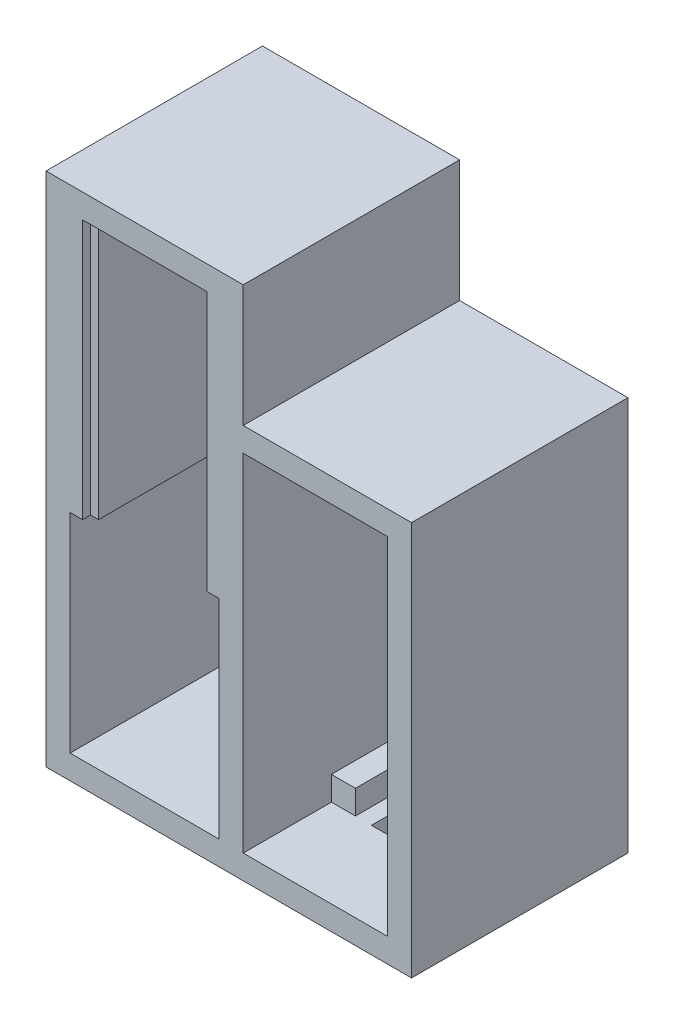
from build123d import *

# Parameters (mm, degrees)
SKETCH1_W            = 24.6
SKETCH1_H            = 64.4
BOSS_EXTRUDE1_DEPTH  = 3
SKETCH1_5_W          = 24.6
SKETCH1_5_H          = 64.4
BOSS_EXTRUDE2_DEPTH  = 26
BOSS_EXTRUDE4_DEPTH  = 35
SKETCH1_8_W          = 24.6
SKETCH1_8_H          = 64.4
BOSS_EXTRUDE5_DEPTH  = 27
BOSS_EXTRUDE6_DEPTH  = 3
BOSS_EXTRUDE7_DEPTH  = 2
SKETCH2_4_W          = 8
SKETCH2_4_H          = 3
BOSS_EXTRUDE8_DEPTH  = 11
SKETCH2_5_W          = 5
SKETCH2_5_H          = 3
BOSS_EXTRUDE9_DEPTH  = 27
SKETCH5_W            = 33.6
SKETCH5_H            = 60.4
BOSS_EXTRUDE11_DEPTH = 3
SKETCH5_5_W          = 30.618778274
SKETCH5_5_H          = 54.4
CUT_EXTRUDE3_DEPTH   = 3
BOSS_EXTRUDE12_DEPTH = 27
SKETCH6_W            = 30.618778274
SKETCH6_H            = 47.4
BOSS_EXTRUDE13_DEPTH = 3
SKETCH7_W            = 24.6
SKETCH7_H            = 8
CUT_EXTRUDE4_DEPTH   = 3
SKETCH8_W            = 11
SKETCH8_H            = 3
BOSS_EXTRUDE14_DEPTH = 8
SKETCH2_6_W          = 3
SKETCH2_6_H          = 3
SKETCH2_6_W_2        = 5
BOSS_EXTRUDE15_DEPTH = 16
SKETCH9_W            = 36.6
SKETCH9_H            = 3
BOSS_EXTRUDE16_DEPTH = 15
SKETCH10_W           = 18.8
SKETCH10_H           = 11.60179211
CUT_EXTRUDE5_DEPTH   = 15
BOSS_EXTRUDE17_DEPTH = 3
BOSS_EXTRUDE18_DEPTH = 3
SKETCH13_W           = 33.6
SKETCH13_H           = 60.4
CUT_EXTRUDE6_DEPTH   = 70
CUT_EXTRUDE7_DEPTH   = 70


with BuildPart() as part:
    # Sketch1 → Boss-Extrude1 (new body)
    with BuildSketch(Plane.XY):
        with Locations((-9.3, 29.2)):
            Rectangle(SKETCH1_W, SKETCH1_H)
    extrude(amount=BOSS_EXTRUDE1_DEPTH)

    # Sketch1_5 → Boss-Extrude2 (add)
    with BuildSketch(Plane.XY):
        with Locations((-9.3, 29.2)):
            Rectangle(SKETCH1_5_W, SKETCH1_5_H)
        Polygon((0, 0), (-18.6, 0), (-18.6, 26), (-16.05, 26), (-16.05, 58.4), (-2.55, 58.4), (-2.55, 26), (0, 26), align=None, mode=Mode.SUBTRACT)
    extrude(amount=BOSS_EXTRUDE2_DEPTH)

    # Sketch1_7 → Boss-Extrude4 (add)
    with BuildSketch(Plane.XY):
        Polygon((3, 0), (0, 0), (-18.6, 0), (-21.6, 0), (-21.6, -3), (3, -3), align=None)
    extrude(amount=BOSS_EXTRUDE4_DEPTH)

    # Sketch1_8 → Boss-Extrude5 (add)
    with BuildSketch(Plane.XY):
        with Locations((-9.3, 29.2)):
            Rectangle(SKETCH1_8_W, SKETCH1_8_H)
        Polygon((0, 0), (-18.6, 0), (-18.6, 26), (-17.05, 26), (-17.05, 58.4), (-1.55, 58.4), (-1.55, 26), (0, 26), align=None, mode=Mode.SUBTRACT)
    extrude(amount=BOSS_EXTRUDE5_DEPTH)

    # Sketch2 → Boss-Extrude6 (add)
    with BuildSketch(Plane(origin=(0, 0, 0), x_dir=(-1, 0, 0), z_dir=(0, 0, -1))):
        Polygon((-8, 0), (-6, 0), (-6, 3), (-3, 3), (-3, 40.2), (-8, 40.2), (-8, 43.2), (-16, 43.2), (-16, 40.2), (-21, 40.2), (-21, 3), (-18, 3), (-18, 0), (-16, 0), align=None)
    extrude(amount=-BOSS_EXTRUDE6_DEPTH)

    # Sketch2_3 → Boss-Extrude7 (add)
    with BuildSketch(Plane(origin=(0, 0, 0), x_dir=(-1, 0, 0), z_dir=(0, 0, -1))):
        Polygon((-3, -3), (-3, 3), (-6, 3), (-6, 0), (-8, 0), (-8, -3), align=None)
        Polygon((-8, 40.2), (-3, 40.2), (-3, 46.2), (-24, 46.2), (-24, -3), (-16, -3), (-16, 0), (-18, 0), (-18, 3), (-21, 3), (-21, 40.2), (-16, 40.2), (-16, 43.2), (-8, 43.2), align=None)
    extrude(amount=-BOSS_EXTRUDE7_DEPTH)

    # Sketch2_4 → Boss-Extrude8 (add)
    with BuildSketch(Plane(origin=(0, 0, 0), x_dir=(-1, 0, 0), z_dir=(0, 0, -1))):
        with Locations((-12, -1.5)):
            Rectangle(SKETCH2_4_W, SKETCH2_4_H)
    extrude(amount=-BOSS_EXTRUDE8_DEPTH)

    # Sketch2_5 → Boss-Extrude9 (add)
    with BuildSketch(Plane(origin=(0, 0, 0), x_dir=(-1, 0, 0), z_dir=(0, 0, -1))):
        with Locations((-5.5, -1.5)):
            Rectangle(SKETCH2_5_W, SKETCH2_5_H)
        Polygon((-16, -3), (-16, 0), (-21, 0), (-21, 43.2), (-3, 43.2), (-3, 46.2), (-24, 46.2), (-24, -3), align=None)
    extrude(amount=-BOSS_EXTRUDE9_DEPTH)

    # Sketch5 → Boss-Extrude11 (add)
    with BuildSketch(Plane(origin=(0, 0, 0), x_dir=(-1, 0, 0), z_dir=(0, 0, -1))):
        with Locations((38.4, 27.2)):
            Rectangle(SKETCH5_W, SKETCH5_H)
    extrude(amount=-BOSS_EXTRUDE11_DEPTH)

    # Sketch5_5 → Cut-Extrude3 (cut)
    with BuildSketch(Plane(origin=(0, 0, 0), x_dir=(-1, 0, 0), z_dir=(0, 0, -1))):
        with Locations((36.909389137, 27.2)):
            Rectangle(SKETCH5_5_W, SKETCH5_5_H)
    extrude(amount=-CUT_EXTRUDE3_DEPTH, mode=Mode.SUBTRACT)

    # Sketch5_6 → Boss-Extrude12 (add)
    with BuildSketch(Plane(origin=(0, 0, 0), x_dir=(-1, 0, 0), z_dir=(0, 0, -1))):
        Polygon((21.6, 0), (21.6, -3), (55.2, -3), (55.2, 57.4), (21.6, 57.4), (21.6, 54.4), (52.218778274, 54.4), (52.218778274, 0), align=None)
    extrude(amount=-BOSS_EXTRUDE12_DEPTH)

    # Sketch6 → Boss-Extrude13 (add)
    with BuildSketch(Plane.XY.offset(27)):
        with Locations((-36.909389137, 23.7)):
            Rectangle(SKETCH6_W, SKETCH6_H)
    extrude(amount=-BOSS_EXTRUDE13_DEPTH)

    # Sketch7 → Cut-Extrude4 (cut)
    with BuildSketch(Plane.XZ.offset(3)):
        with Locations((-9.3, 31)):
            Rectangle(SKETCH7_W, SKETCH7_H)
    extrude(amount=-CUT_EXTRUDE4_DEPTH, mode=Mode.SUBTRACT)

    # Sketch8 → Boss-Extrude14 (add)
    with BuildSketch(Plane(origin=(8, 0, 0), x_dir=(0, 0, -1), z_dir=(1, 0, 0))):
        with Locations((-21.5, -1.5)):
            Rectangle(SKETCH8_W, SKETCH8_H)
    extrude(amount=BOSS_EXTRUDE14_DEPTH)

    # Sketch2_6 → Boss-Extrude15 (add)
    with BuildSketch(Plane(origin=(0, 0, 0), x_dir=(-1, 0, 0), z_dir=(0, 0, -1))):
        with Locations((-4.5, 1.5)):
            Rectangle(SKETCH2_6_W, SKETCH2_6_H)
        with Locations((-5.5, 41.7)):
            Rectangle(SKETCH2_6_W_2, SKETCH2_6_H)
        with Locations((-19.5, 1.5)):
            Rectangle(SKETCH2_6_W, SKETCH2_6_H)
        with Locations((-18.5, 41.7)):
            Rectangle(SKETCH2_6_W_2, SKETCH2_6_H)
    extrude(amount=-BOSS_EXTRUDE15_DEPTH)

    # Sketch9 → Boss-Extrude16 (add)
    with BuildSketch(Plane.XY.offset(27)):
        with Locations((-36.9, -1.5)):
            Rectangle(SKETCH9_W, SKETCH9_H)
    extrude(amount=BOSS_EXTRUDE16_DEPTH)

    # Sketch10 → Cut-Extrude5 (cut)
    with BuildSketch(Plane(origin=(0, -3, 0), x_dir=(-1, 0, 0), z_dir=(0, -1, 0))):
        with Locations((39.656308117, -34.500896055)):
            Rectangle(SKETCH10_W, SKETCH10_H)
    extrude(amount=-CUT_EXTRUDE5_DEPTH, mode=Mode.SUBTRACT)

    # Sketch11 → Boss-Extrude17 (add)
    with BuildSketch(Plane(origin=(0, -3, 0), x_dir=(-1, 0, 0), z_dir=(0, -1, 0))):
        Polygon((18.6, -42), (18.6, -27), (3.6, -27), align=None)
    extrude(amount=-BOSS_EXTRUDE17_DEPTH)

    # Sketch12 → Boss-Extrude18 (add)
    with BuildSketch(Plane.ZY.offset(55.2)):
        Polygon((27, 0), (42, 0), (27, 15), align=None)
    extrude(amount=-BOSS_EXTRUDE18_DEPTH)

    # Sketch13 → Cut-Extrude6 (cut)
    with BuildSketch(Plane.XY.offset(42)):
        with Locations((-38.4, 27.2)):
            Rectangle(SKETCH13_W, SKETCH13_H)
    extrude(amount=-CUT_EXTRUDE6_DEPTH, mode=Mode.SUBTRACT)

    # Sketch14 → Cut-Extrude7 (cut)
    with BuildSketch(Plane(origin=(0, -3, 0), x_dir=(-1, 0, 0), z_dir=(0, -1, 0))):
        Polygon((3.6, -27), (21.6, -27), (21.6, -42), (18.6, -42), align=None)
    extrude(amount=-CUT_EXTRUDE7_DEPTH, mode=Mode.SUBTRACT)


solid = part.part
